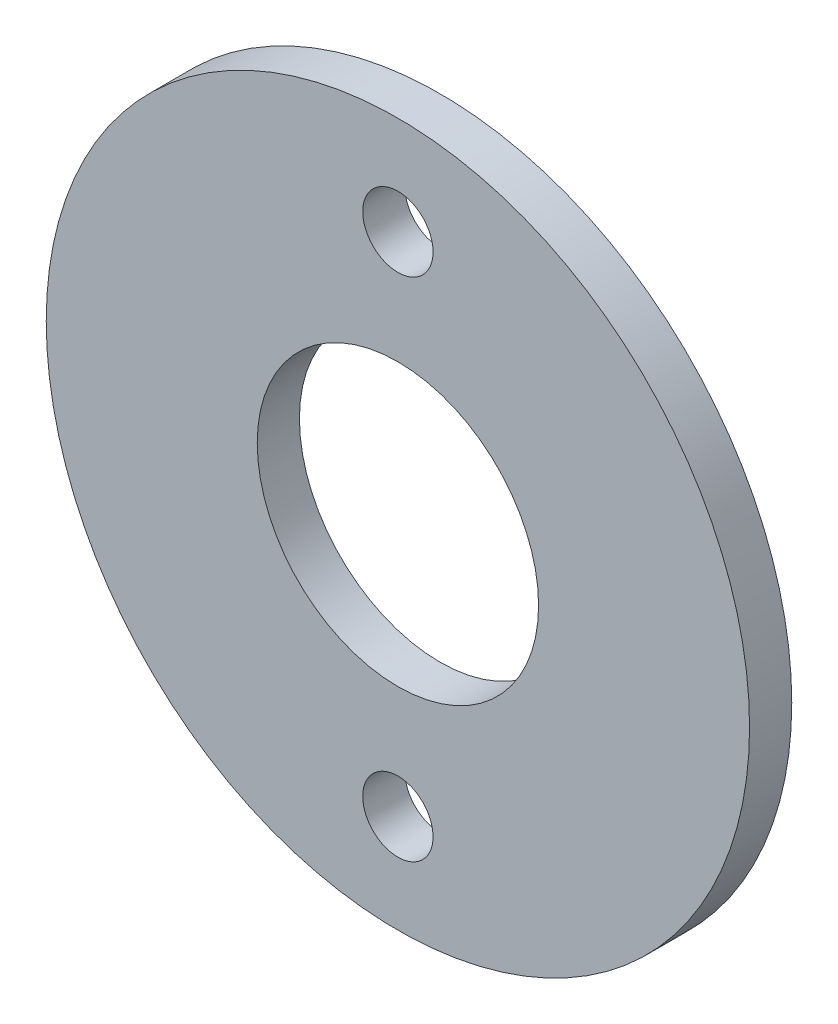
from build123d import *

# Parameters (mm, degrees)
CROQUIS1_R              = 12.5
CROQUIS1_R_2            = 5
SALIENTE_EXTRUIR1_DEPTH = 1.5
CROQUIS2_R              = 1.25
CORTAR_EXTRUIR1_DEPTH   = 2.5


with BuildPart() as part:
    # Croquis1 → Saliente-Extruir1 (new body)
    with BuildSketch(Plane.XY):
        Circle(CROQUIS1_R)
        Circle(CROQUIS1_R_2, mode=Mode.SUBTRACT)
    extrude(amount=SALIENTE_EXTRUIR1_DEPTH)

    # Croquis2 → Cortar-Extruir1 (cut, through all)
    with BuildSketch(Plane.XY.offset(1.5)):
        with Locations((0, 9)):
            Circle(CROQUIS2_R)
        with Locations((0, -9)):
            Circle(CROQUIS2_R)
    extrude(amount=-CORTAR_EXTRUIR1_DEPTH, mode=Mode.SUBTRACT)


solid = part.part
